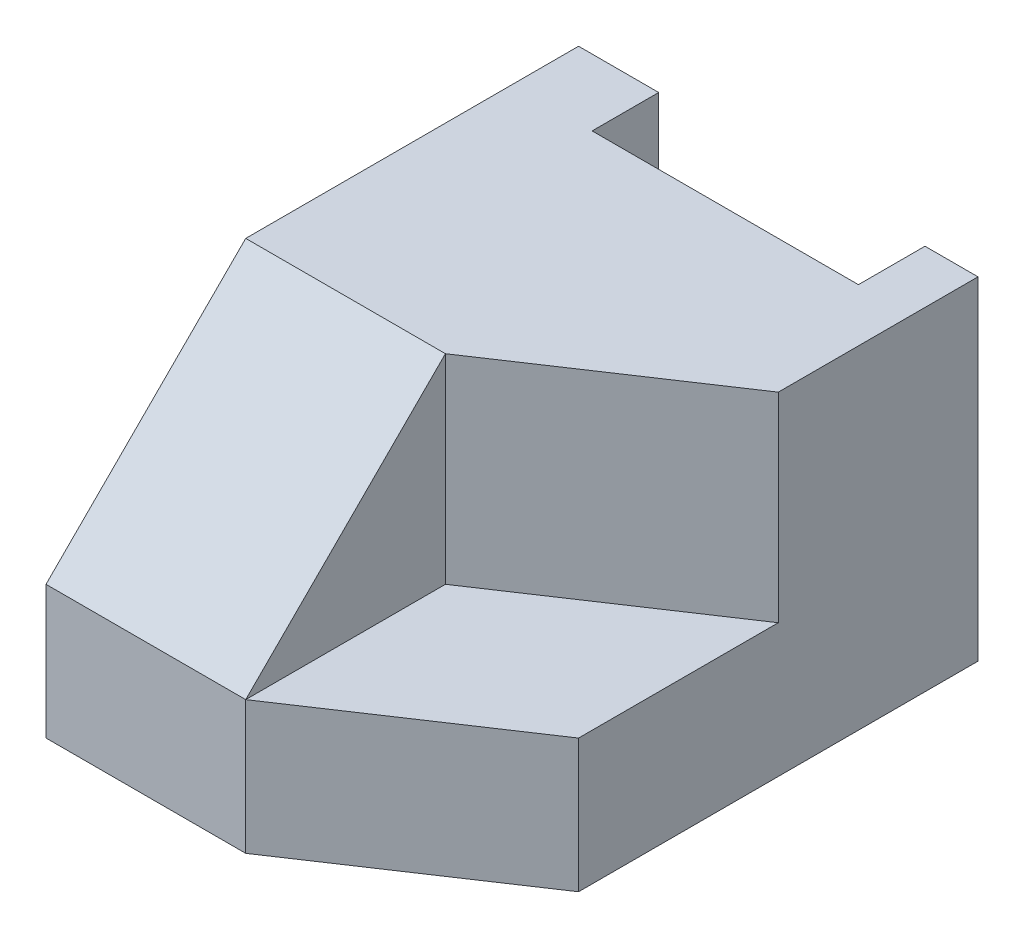
from build123d import *

# Parameters (mm, degrees)
SKETCH1_W           = 60
SKETCH1_H           = 80
BOSS_EXTRUDE1_DEPTH = 50
SKETCH2_W           = 40
SKETCH2_H           = 10
CUT_EXTRUDE1_DEPTH  = 50
CUT_EXTRUDE2_DEPTH  = 30
CUT_EXTRUDE3_DEPTH  = 30
CHAMFER1_SIZE       = 30


with BuildPart() as part:
    # Sketch1 → Boss-Extrude1 (new body)
    with BuildSketch(Plane(origin=(0, 0, 0), x_dir=(1, 0, 0), z_dir=(0, 1, 0))):
        Rectangle(SKETCH1_W, SKETCH1_H)
    extrude(amount=BOSS_EXTRUDE1_DEPTH)

    # Sketch2 → Cut-Extrude1 (cut)
    with BuildSketch(Plane(origin=(0, 50, 0), x_dir=(1, 0, 0), z_dir=(0, 1, 0))):
        with Locations((2.037233821, 35)):
            Rectangle(SKETCH2_W, SKETCH2_H)
    extrude(amount=-CUT_EXTRUDE1_DEPTH, mode=Mode.SUBTRACT)

    # Sketch3 → Cut-Extrude2 (cut)
    with BuildSketch(Plane(origin=(0, 50, 0), x_dir=(1, 0, 0), z_dir=(0, 1, 0))):
        Polygon((0, -10), (30, 10), (30, -40), (0, -40), align=None)
    extrude(amount=-CUT_EXTRUDE2_DEPTH, mode=Mode.SUBTRACT)

    # Sketch4 → Cut-Extrude3 (cut)
    with BuildSketch(Plane(origin=(0, 20, 0), x_dir=(1, 0, 0), z_dir=(0, 1, 0))):
        Polygon((0, -40), (30, -20), (30, -40), align=None)
    extrude(amount=-CUT_EXTRUDE3_DEPTH, mode=Mode.SUBTRACT)

    # Chamfer1
    chamfer1_edges = [part.edges().sort_by_distance(p)[0] for p in [
        (-15, 50, 40),
    ]]
    chamfer(chamfer1_edges, length=CHAMFER1_SIZE)


solid = part.part
